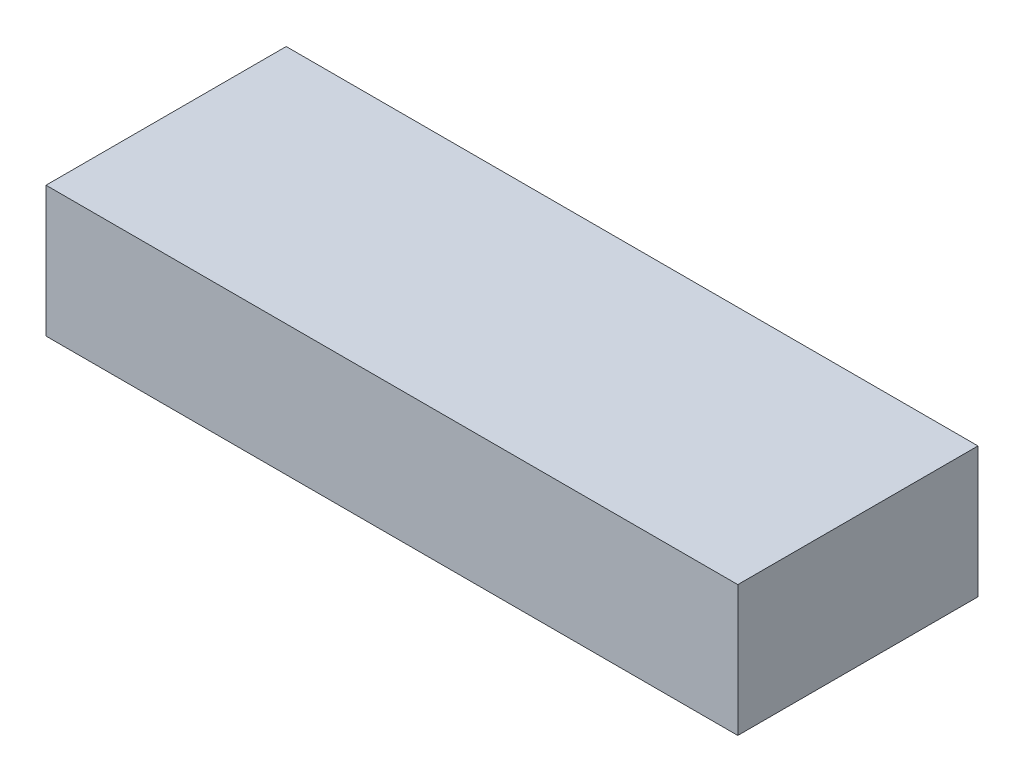
from build123d import *

# Parameters (mm, degrees)
SKETCH1_W           = 72
SKETCH1_H           = 25
BOSS_EXTRUDE1_DEPTH = 13.6


with BuildPart() as part:
    # Sketch1 → Boss-Extrude1 (new body)
    with BuildSketch(Plane(origin=(0, 0, 0), x_dir=(1, 0, 0), z_dir=(0, 1, 0))):
        Rectangle(SKETCH1_W, SKETCH1_H)
    extrude(amount=BOSS_EXTRUDE1_DEPTH)


solid = part.part
